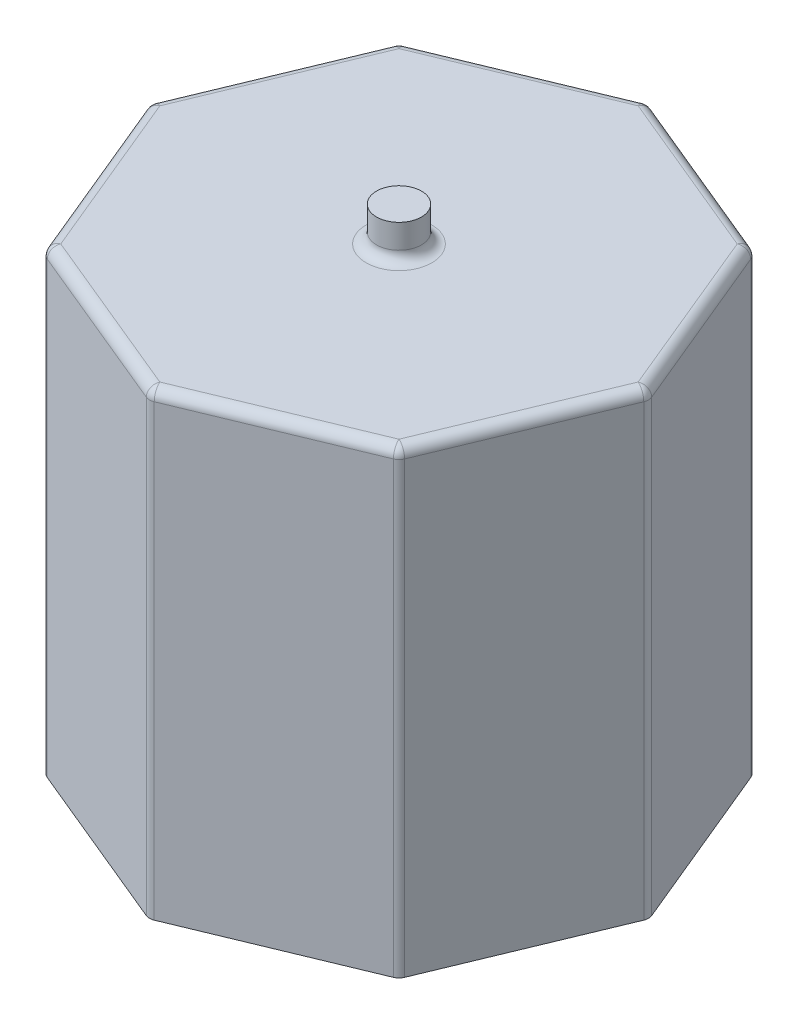
from build123d import *

# Parameters (mm, degrees)
BOSS_EXTRUDE1_DEPTH = 13.3
SKETCH2_R           = 0.65
BOSS_EXTRUDE2_DEPTH = 1
FILLET1_R           = 0.3
FILLET2_R           = 0.3


with BuildPart() as part:
    # Sketch1 → Boss-Extrude1 (new body)
    with BuildSketch(Plane(origin=(0, 0, 0), x_dir=(1, 0, 0), z_dir=(0, 1, 0))):
        Polygon((7.25, 0), (5.126524164, 5.126524164), (0, 7.25), (-5.126524164, 5.126524164), (-7.25, 0), (-5.126524164, -5.126524164), (0, -7.25), (5.126524164, -5.126524164), align=None)
    extrude(amount=BOSS_EXTRUDE1_DEPTH)

    # Sketch2 → Boss-Extrude2 (add)
    with BuildSketch(Plane(origin=(0, 13.3, 0), x_dir=(1, 0, 0), z_dir=(0, 1, 0))):
        with Locations(Location((0, 0, 0), (0, 0, 270))):  # turned: the seam where the file's is
            Circle(SKETCH2_R)
    extrude(amount=BOSS_EXTRUDE2_DEPTH)

    # Fillet1
    fillet1_edges = [part.edges().sort_by_distance(p)[0] for p in [
        (5.126524164, 6.65, 5.126524164),
        (0, 6.65, 7.25),
        (-5.126524164, 6.65, 5.126524164),
        (-7.25, 6.65, 0),
        (-5.126524164, 6.65, -5.126524164),
        (0, 6.65, -7.25),
        (5.126524164, 6.65, -5.126524164),
        (7.25, 6.65, 0),
    ]]
    fillet(fillet1_edges, radius=FILLET1_R)

    # Fillet2
    fillet2_edges = [part.edges().sort_by_distance(p)[0] for p in [
        (0, 13.3, -0.65),
        (-2.563262082, 13.3, 6.188262082),
        (-6.188262082, 13.3, 2.563262082),
        (6.188262082, 13.3, 2.563262082),
        (6.188262082, 13.3, -2.563262082),
        (2.563262082, 13.3, -6.188262082),
        (-2.563262082, 13.3, -6.188262082),
        (-6.188262082, 13.3, -2.563262082),
        (2.563262082, 13.3, 6.188262082),
        (0, 13.3, 7.22528234),
        (5.109046139, 13.3, 5.109046139),
        (7.22528234, 13.3, 0),
        (5.109046139, 13.3, -5.109046139),
        (0, 13.3, -7.22528234),
        (-5.109046139, 13.3, -5.109046139),
        (-7.22528234, 13.3, 0),
        (-5.109046139, 13.3, 5.109046139),
    ]]
    fillet(fillet2_edges, radius=FILLET2_R)


solid = part.part
